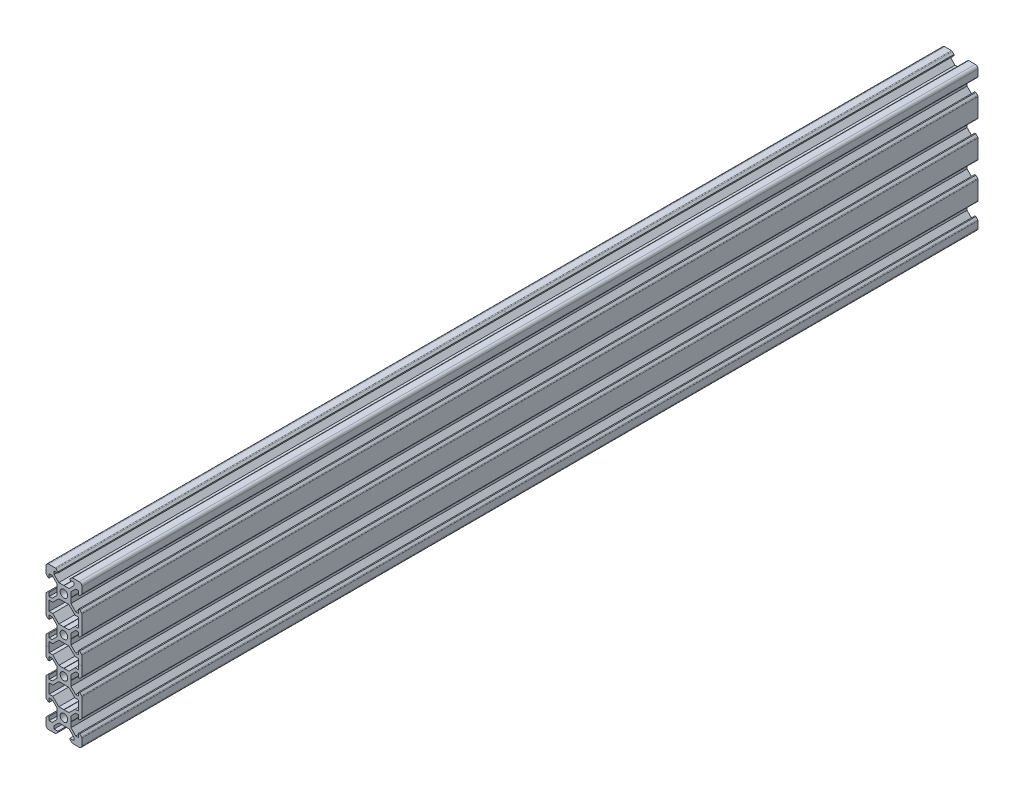
from build123d import *

# Parameters (mm, degrees)
SKETCH1_R           = 2.1
BOSS_EXTRUDE2_DEPTH = 500


with BuildPart() as part:
    # Sketch1 → Boss-Extrude2 (new body)
    with BuildSketch(Plane.XY):
        with BuildLine():
            Line((-8.5, 10), (-4.862792737, 10))
            ThreePointArc((-4.862792737, 10), (-4.598292737, 9.947387679), (-4.374060464, 9.797560464))
            Line((-4.374060464, 9.797560464), (-3.3865, 8.81))
            Line((-3.3865, 8.81), (-3.3865, 8.2))
            Line((-3.3865, 8.2), (-5.5, 8.2))
            Line((-5.5, 8.2), (-5.5, 6.561))
            Line((-5.5, 6.561), (-2.8395, 3.9005))
            Line((-2.8395, 3.9005), (-0.1, 3.9005))
            Line((-0.1, 3.9005), (0, 3.8005))
            Line((0, 3.8005), (0.1, 3.9005))
            Line((0.1, 3.9005), (2.8395, 3.9005))
            Line((2.8395, 3.9005), (5.5, 6.561))
            Line((5.5, 6.561), (5.5, 8.2))
            Line((5.5, 8.2), (3.3865, 8.2))
            Line((3.3865, 8.2), (3.3865, 8.81))
            Line((3.3865, 8.81), (4.374060464, 9.797560464))
            ThreePointArc((4.374060464, 9.797560464), (4.598292737, 9.947387679), (4.862792737, 10))
            Line((4.862792737, 10), (8.5, 10))
            ThreePointArc((8.5, 10), (9.560660172, 9.560660172), (10, 8.5))
            Line((10, 8.5), (10, 4.862792737))
            ThreePointArc((10, 4.862792737), (9.947387679, 4.598292737), (9.797560464, 4.374060464))
            Line((9.797560464, 4.374060464), (8.81, 3.3865))
            Line((8.81, 3.3865), (8.2, 3.3865))
            Line((8.2, 3.3865), (8.2, 5.5))
            Line((8.2, 5.5), (6.561, 5.5))
            Line((6.561, 5.5), (3.9005, 2.8395))
            Line((3.9005, 2.8395), (3.9005, 0.1))
            Line((3.9005, 0.1), (3.8005, 0))
            Line((3.8005, 0), (3.9005, -0.1))
            Line((3.9005, -0.1), (3.9005, -2.8395))
            Line((3.9005, -2.8395), (6.561, -5.5))
            Line((6.561, -5.5), (8.2, -5.5))
            Line((8.2, -5.5), (8.2, -3.3865))
            Line((8.2, -3.3865), (8.81, -3.3865))
            Line((8.81, -3.3865), (9.797560464, -4.374060464))
            ThreePointArc((9.797560464, -4.374060464), (9.947387679, -4.598292737), (10, -4.862792737))
            Line((10, -4.862792737), (10, -15.137207263))
            ThreePointArc((10, -15.137207263), (9.947387679, -15.401707263), (9.797560464, -15.625939536))
            Line((9.797560464, -15.625939536), (8.81, -16.6135))
            Line((8.81, -16.6135), (8.2, -16.6135))
            Line((8.2, -16.6135), (8.2, -14.5))
            Line((8.2, -14.5), (6.561, -14.5))
            Line((6.561, -14.5), (3.9005, -17.1605))
            Line((3.9005, -17.1605), (3.9005, -19.9))
            Line((3.9005, -19.9), (3.8005, -20))
            Line((3.8005, -20), (3.9005, -20.1))
            Line((3.9005, -20.1), (3.9005, -22.8395))
            Line((3.9005, -22.8395), (6.561, -25.5))
            Line((6.561, -25.5), (8.2, -25.5))
            Line((8.2, -25.5), (8.2, -23.3865))
            Line((8.2, -23.3865), (8.81, -23.3865))
            Line((8.81, -23.3865), (9.797560464, -24.374060464))
            ThreePointArc((9.797560464, -24.374060464), (9.947387679, -24.598292737), (10, -24.862792737))
            Line((10, -24.862792737), (10, -35.137207263))
            ThreePointArc((10, -35.137207263), (9.947387679, -35.401707263), (9.797560464, -35.625939536))
            Line((9.797560464, -35.625939536), (8.81, -36.6135))
            Line((8.81, -36.6135), (8.2, -36.6135))
            Line((8.2, -36.6135), (8.2, -34.5))
            Line((8.2, -34.5), (6.561, -34.5))
            Line((6.561, -34.5), (3.9005, -37.1605))
            Line((3.9005, -37.1605), (3.9005, -39.9))
            Line((3.9005, -39.9), (3.8005, -40))
            Line((3.8005, -40), (3.9005, -40.1))
            Line((3.9005, -40.1), (3.9005, -42.8395))
            Line((3.9005, -42.8395), (6.561, -45.5))
            Line((6.561, -45.5), (8.2, -45.5))
            Line((8.2, -45.5), (8.2, -43.3865))
            Line((8.2, -43.3865), (8.81, -43.3865))
            Line((8.81, -43.3865), (9.797560464, -44.374060464))
            ThreePointArc((9.797560464, -44.374060464), (9.947387679, -44.598292737), (10, -44.862792737))
            Line((10, -44.862792737), (10, -55.137207263))
            ThreePointArc((10, -55.137207263), (9.947387679, -55.401707263), (9.797560464, -55.625939536))
            Line((9.797560464, -55.625939536), (8.81, -56.6135))
            Line((8.81, -56.6135), (8.2, -56.6135))
            Line((8.2, -56.6135), (8.2, -54.5))
            Line((8.2, -54.5), (6.561, -54.5))
            Line((6.561, -54.5), (3.9005, -57.1605))
            Line((3.9005, -57.1605), (3.9005, -59.9))
            Line((3.9005, -59.9), (3.8005, -60))
            Line((3.8005, -60), (3.9005, -60.1))
            Line((3.9005, -60.1), (3.9005, -62.8395))
            Line((3.9005, -62.8395), (6.561, -65.5))
            Line((6.561, -65.5), (8.2, -65.5))
            Line((8.2, -65.5), (8.2, -63.3865))
            Line((8.2, -63.3865), (8.81, -63.3865))
            Line((8.81, -63.3865), (9.797560464, -64.374060464))
            ThreePointArc((9.797560464, -64.374060464), (9.947387679, -64.598292737), (10, -64.862792737))
            Line((10, -64.862792737), (10, -68.5))
            ThreePointArc((10, -68.5), (9.560660172, -69.560660172), (8.5, -70))
            Line((8.5, -70), (4.862792737, -70))
            ThreePointArc((4.862792737, -70), (4.598292737, -69.947387679), (4.374060464, -69.797560464))
            Line((4.374060464, -69.797560464), (3.3865, -68.81))
            Line((3.3865, -68.81), (3.3865, -68.2))
            Line((3.3865, -68.2), (5.5, -68.2))
            Line((5.5, -68.2), (5.5, -66.561))
            Line((5.5, -66.561), (2.8395, -63.9005))
            Line((2.8395, -63.9005), (0.1, -63.9005))
            Line((0.1, -63.9005), (0, -63.8005))
            Line((0, -63.8005), (-0.1, -63.9005))
            Line((-0.1, -63.9005), (-2.8395, -63.9005))
            Line((-2.8395, -63.9005), (-5.5, -66.561))
            Line((-5.5, -66.561), (-5.5, -68.2))
            Line((-5.5, -68.2), (-3.3865, -68.2))
            Line((-3.3865, -68.2), (-3.3865, -68.81))
            Line((-3.3865, -68.81), (-4.374060464, -69.797560464))
            ThreePointArc((-4.374060464, -69.797560464), (-4.598292737, -69.947387679), (-4.862792737, -70))
            Line((-4.862792737, -70), (-8.5, -70))
            ThreePointArc((-8.5, -70), (-9.560660172, -69.560660172), (-10, -68.5))
            Line((-10, -68.5), (-10, -64.862792737))
            ThreePointArc((-10, -64.862792737), (-9.947387679, -64.598292737), (-9.797560464, -64.374060464))
            Line((-9.797560464, -64.374060464), (-8.81, -63.3865))
            Line((-8.81, -63.3865), (-8.2, -63.3865))
            Line((-8.2, -63.3865), (-8.2, -65.5))
            Line((-8.2, -65.5), (-6.561, -65.5))
            Line((-6.561, -65.5), (-3.9005, -62.8395))
            Line((-3.9005, -62.8395), (-3.9005, -60.1))
            Line((-3.9005, -60.1), (-3.8005, -60))
            Line((-3.8005, -60), (-3.9005, -59.9))
            Line((-3.9005, -59.9), (-3.9005, -57.1605))
            Line((-3.9005, -57.1605), (-6.561, -54.5))
            Line((-6.561, -54.5), (-8.2, -54.5))
            Line((-8.2, -54.5), (-8.2, -56.6135))
            Line((-8.2, -56.6135), (-8.81, -56.6135))
            Line((-8.81, -56.6135), (-9.797560464, -55.625939536))
            ThreePointArc((-9.797560464, -55.625939536), (-9.947387679, -55.401707263), (-10, -55.137207263))
            Line((-10, -55.137207263), (-10, -44.862792737))
            ThreePointArc((-10, -44.862792737), (-9.947387679, -44.598292737), (-9.797560464, -44.374060464))
            Line((-9.797560464, -44.374060464), (-8.81, -43.3865))
            Line((-8.81, -43.3865), (-8.2, -43.3865))
            Line((-8.2, -43.3865), (-8.2, -45.5))
            Line((-8.2, -45.5), (-6.561, -45.5))
            Line((-6.561, -45.5), (-3.9005, -42.8395))
            Line((-3.9005, -42.8395), (-3.9005, -40.1))
            Line((-3.9005, -40.1), (-3.8005, -40))
            Line((-3.8005, -40), (-3.9005, -39.9))
            Line((-3.9005, -39.9), (-3.9005, -37.1605))
            Line((-3.9005, -37.1605), (-6.561, -34.5))
            Line((-6.561, -34.5), (-8.2, -34.5))
            Line((-8.2, -34.5), (-8.2, -36.6135))
            Line((-8.2, -36.6135), (-8.81, -36.6135))
            Line((-8.81, -36.6135), (-9.797560464, -35.625939536))
            ThreePointArc((-9.797560464, -35.625939536), (-9.947387679, -35.401707263), (-10, -35.137207263))
            Line((-10, -35.137207263), (-10, -24.862792737))
            ThreePointArc((-10, -24.862792737), (-9.947387679, -24.598292737), (-9.797560464, -24.374060464))
            Line((-9.797560464, -24.374060464), (-8.81, -23.3865))
            Line((-8.81, -23.3865), (-8.2, -23.3865))
            Line((-8.2, -23.3865), (-8.2, -25.5))
            Line((-8.2, -25.5), (-6.561, -25.5))
            Line((-6.561, -25.5), (-3.9005, -22.8395))
            Line((-3.9005, -22.8395), (-3.9005, -20.1))
            Line((-3.9005, -20.1), (-3.8005, -20))
            Line((-3.8005, -20), (-3.9005, -19.9))
            Line((-3.9005, -19.9), (-3.9005, -17.1605))
            Line((-3.9005, -17.1605), (-6.561, -14.5))
            Line((-6.561, -14.5), (-8.2, -14.5))
            Line((-8.2, -14.5), (-8.2, -16.6135))
            Line((-8.2, -16.6135), (-8.81, -16.6135))
            Line((-8.81, -16.6135), (-9.797560464, -15.625939536))
            ThreePointArc((-9.797560464, -15.625939536), (-9.947387679, -15.401707263), (-10, -15.137207263))
            Line((-10, -15.137207263), (-10, -4.862792737))
            ThreePointArc((-10, -4.862792737), (-9.947387679, -4.598292737), (-9.797560464, -4.374060464))
            Line((-9.797560464, -4.374060464), (-8.81, -3.3865))
            Line((-8.81, -3.3865), (-8.2, -3.3865))
            Line((-8.2, -3.3865), (-8.2, -5.5))
            Line((-8.2, -5.5), (-6.561, -5.5))
            Line((-6.561, -5.5), (-3.9005, -2.8395))
            Line((-3.9005, -2.8395), (-3.9005, -0.1))
            Line((-3.9005, -0.1), (-3.8005, 0))
            Line((-3.8005, 0), (-3.9005, 0.1))
            Line((-3.9005, 0.1), (-3.9005, 2.8395))
            Line((-3.9005, 2.8395), (-6.561, 5.5))
            Line((-6.561, 5.5), (-8.2, 5.5))
            Line((-8.2, 5.5), (-8.2, 3.3865))
            Line((-8.2, 3.3865), (-8.81, 3.3865))
            Line((-8.81, 3.3865), (-9.797560464, 4.374060464))
            ThreePointArc((-9.797560464, 4.374060464), (-9.947387679, 4.598292737), (-10, 4.862792737))
            Line((-10, 4.862792737), (-10, 8.5))
            ThreePointArc((-10, 8.5), (-9.560660172, 9.560660172), (-8.5, 10))
        make_face()
        Circle(SKETCH1_R, mode=Mode.SUBTRACT)
        with Locations((0, -20)):
            Circle(SKETCH1_R, mode=Mode.SUBTRACT)
        with Locations((0, -40)):
            Circle(SKETCH1_R, mode=Mode.SUBTRACT)
        with Locations((0, -60)):
            Circle(SKETCH1_R, mode=Mode.SUBTRACT)
        Polygon((-8.2, -12.7), (-8.2, -7.3), (-6.239, -7.3), (-5.5, -6.561), (-2.8395, -3.9005), (-0.1, -3.9005), (0, -3.8005), (0.1, -3.9005), (2.8395, -3.9005), (5.5, -6.561), (6.239, -7.3), (8.2, -7.3), (8.2, -12.7), (6.239, -12.7), (5.5, -13.439), (2.8395, -16.0995), (0.1, -16.0995), (0, -16.1995), (-0.1, -16.0995), (-2.8395, -16.0995), (-5.5, -13.439), (-6.239, -12.7), align=None, mode=Mode.SUBTRACT)
        Polygon((2.8395, -23.9005), (5.5, -26.561), (6.239, -27.3), (8.2, -27.3), (8.2, -32.7), (6.239, -32.7), (5.5, -33.439), (2.8395, -36.0995), (0.1, -36.0995), (0, -36.1995), (-0.1, -36.0995), (-2.8395, -36.0995), (-5.5, -33.439), (-6.239, -32.7), (-8.2, -32.7), (-8.2, -27.3), (-6.239, -27.3), (-5.5, -26.561), (-2.8395, -23.9005), (-0.1, -23.9005), (0, -23.8005), (0.1, -23.9005), align=None, mode=Mode.SUBTRACT)
        Polygon((-0.1, -56.0995), (0, -56.1995), (0.1, -56.0995), (2.8395, -56.0995), (5.5, -53.439), (6.239, -52.7), (8.2, -52.7), (8.2, -47.3), (6.239, -47.3), (5.5, -46.561), (2.8395, -43.9005), (0.1, -43.9005), (0, -43.8005), (-0.1, -43.9005), (-2.8395, -43.9005), (-5.5, -46.561), (-6.239, -47.3), (-8.2, -47.3), (-8.2, -52.7), (-6.239, -52.7), (-5.5, -53.439), (-2.8395, -56.0995), align=None, mode=Mode.SUBTRACT)
    extrude(amount=BOSS_EXTRUDE2_DEPTH)


solid = part.part
